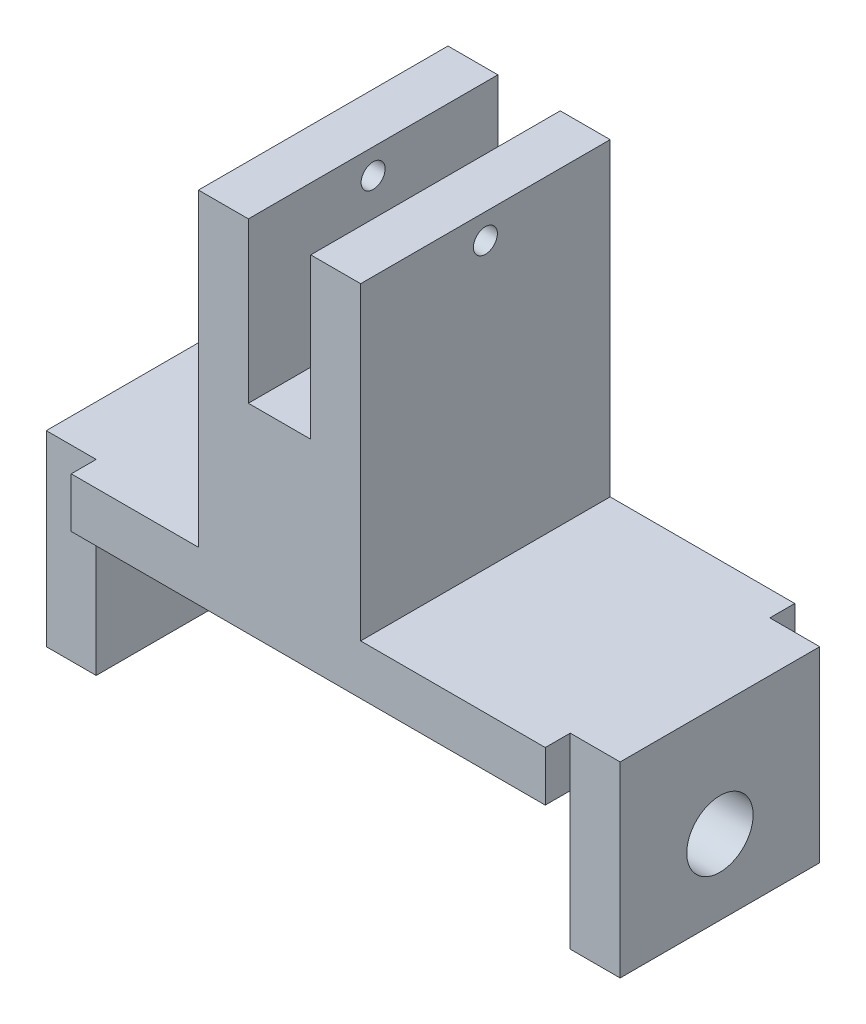
from build123d import *

# Parameters (mm, degrees)
SKETCH1_W           = 48.26
SKETCH1_H           = 25.4
BOSS_EXTRUDE1_DEPTH = 5.08
SKETCH3_W           = 5.08
SKETCH3_H           = 25.4
BOSS_EXTRUDE2_DEPTH = 31.496
SKETCH4_R           = 1.2192
CUT_EXTRUDE2_DEPTH  = 30.464
SKETCH5_W           = 25.4
SKETCH5_H           = 15.24
BOSS_EXTRUDE3_DEPTH = 16.51
SKETCH6_W           = 20.32
SKETCH6_H           = 19.05
BOSS_EXTRUDE4_DEPTH = 5.08
SKETCH7_W           = 20.32
SKETCH7_H           = 19.05
BOSS_EXTRUDE5_DEPTH = 5.08
SKETCH8_R           = 3.3782
CUT_EXTRUDE3_DEPTH  = 6.35
SKETCH9_R           = 3.3782
CUT_EXTRUDE4_DEPTH  = 6.35


with BuildPart() as part:
    # Sketch1 → Boss-Extrude1 (new body)
    with BuildSketch(Plane(origin=(0, 0, 0), x_dir=(1, 0, 0), z_dir=(0, 1, 0))):
        with Locations((24.13, 12.7)):
            Rectangle(SKETCH1_W, SKETCH1_H)
    extrude(amount=BOSS_EXTRUDE1_DEPTH)

    # Sketch3 → Boss-Extrude2 (add)
    with BuildSketch(Plane(origin=(0, 5.08, 0), x_dir=(1, 0, 0), z_dir=(0, 1, 0))):
        with Locations((26.924, 12.7)):
            Rectangle(SKETCH3_W, SKETCH3_H)
        with Locations((15.494, 12.7)):
            Rectangle(SKETCH3_W, SKETCH3_H)
    extrude(amount=BOSS_EXTRUDE2_DEPTH)

    # Sketch4 → Cut-Extrude2 (cut, through all)
    with BuildSketch(Plane(origin=(29.464, 0, 0), x_dir=(0, 0, -1), z_dir=(1, 0, 0))):
        with Locations((12.7, 34.036)):
            Circle(SKETCH4_R)
    extrude(amount=-CUT_EXTRUDE2_DEPTH, mode=Mode.SUBTRACT)

    # Sketch5 → Boss-Extrude3 (add)
    with BuildSketch(Plane(origin=(29.464, 0, 0), x_dir=(0, 0, -1), z_dir=(1, 0, 0))):
        with Locations((12.7, 12.7)):
            Rectangle(SKETCH5_W, SKETCH5_H)
    extrude(amount=-BOSS_EXTRUDE3_DEPTH)

    # Sketch6 → Boss-Extrude4 (add)
    with BuildSketch(Plane.ZY):
        with Locations((-12.7, -4.445)):
            Rectangle(SKETCH6_W, SKETCH6_H)
    extrude(amount=BOSS_EXTRUDE4_DEPTH)

    # Sketch7 → Boss-Extrude5 (add)
    with BuildSketch(Plane(origin=(48.26, 0, 0), x_dir=(0, 0, -1), z_dir=(1, 0, 0))):
        with Locations((12.7, -4.445)):
            Rectangle(SKETCH7_W, SKETCH7_H)
    extrude(amount=BOSS_EXTRUDE5_DEPTH)

    # Sketch8 → Cut-Extrude3 (cut)
    with BuildSketch(Plane(origin=(53.34, 0, 0), x_dir=(0, 0, -1), z_dir=(1, 0, 0))):
        with Locations((12.7, -6.35)):
            Circle(SKETCH8_R)
    extrude(amount=-CUT_EXTRUDE3_DEPTH, mode=Mode.SUBTRACT)

    # Sketch9 → Cut-Extrude4 (cut)
    with BuildSketch(Plane.ZY.offset(5.08)):
        with Locations((-12.7, -6.35)):
            Circle(SKETCH9_R)
    extrude(amount=-CUT_EXTRUDE4_DEPTH, mode=Mode.SUBTRACT)


solid = part.part
